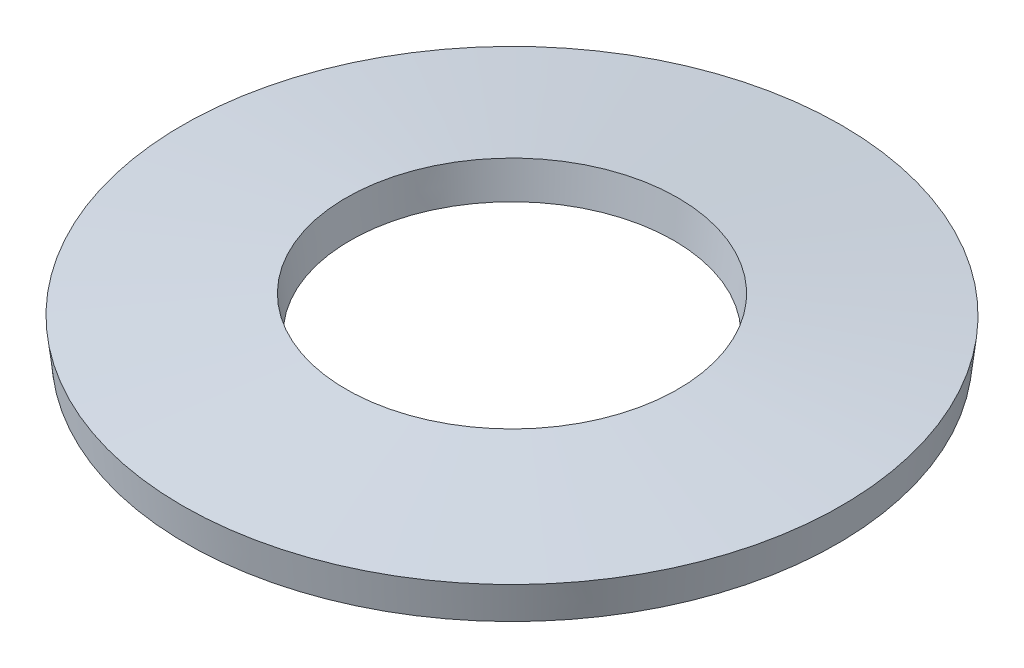
from build123d import *


with BuildPart() as part:
    # Sketch1 → Revolve1 (revolve)
    with BuildSketch(Plane.XY):
        Polygon((3.52476232, 0), (1.7526, 0.20574197), (1.79653768, 0.5842), (3.5687, 0.37845803), align=None)
    revolve(axis=Axis((0, 0, 0), (0, 1, 0)))


solid = part.part
